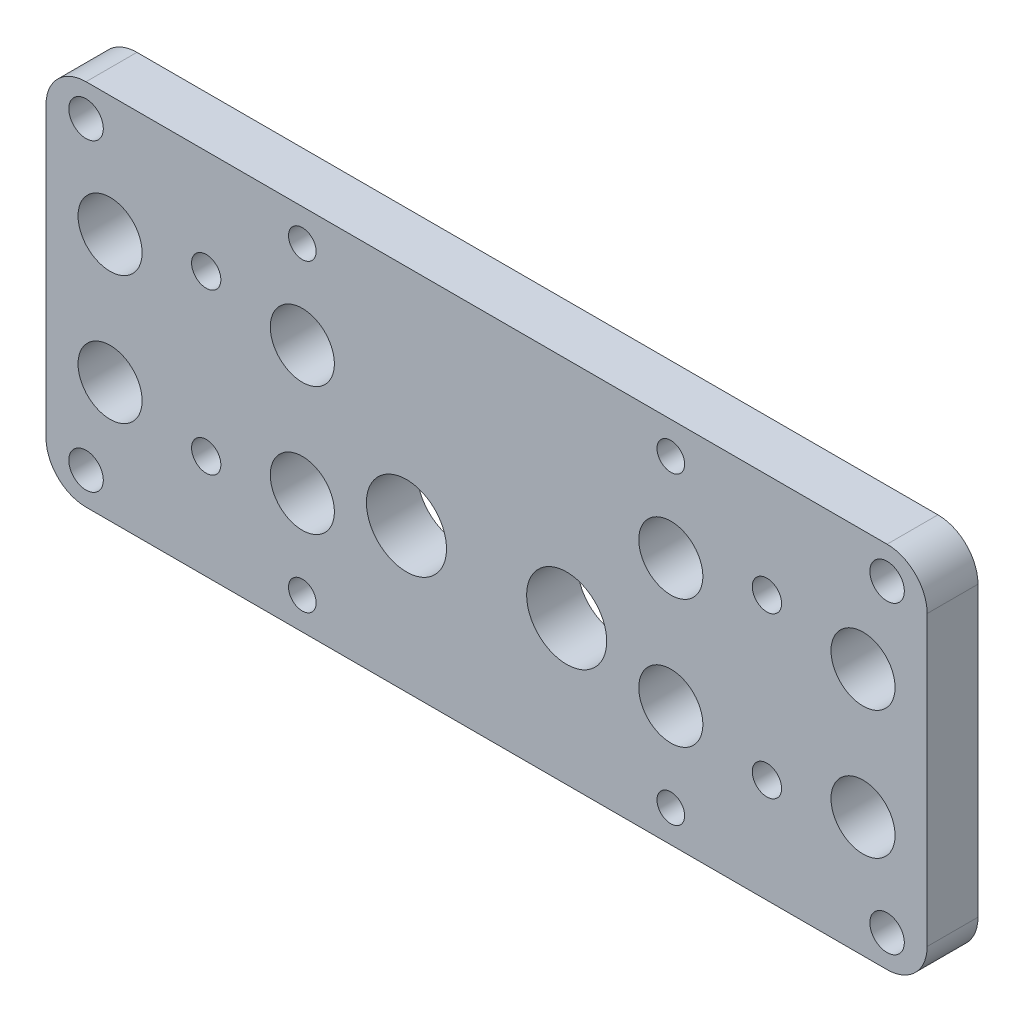
from build123d import *

# Parameters (mm, degrees)
SKETCH1_W             = 110
SKETCH1_H             = 46
BOSS_EXTRUDE1_DEPTH   = 6.35
SKETCH5_R             = 5
CUT_EXTRUDE1_DEPTH    = 7.35
SKETCH7_R             = 4
CUT_EXTRUDE2_DEPTH    = 7.35
FILLET1_R             = 5
F_8_32_TAPPED_HOLE1_D = 3.4544
F_8_CLEARANCE_HOLE1_D = 4.3053
F_6_CLEARANCE_HOLE2_D = 3.6576


with BuildPart() as part:
    # Sketch1 → Boss-Extrude1 (new body)
    with BuildSketch(Plane.XY):
        Rectangle(SKETCH1_W, SKETCH1_H)
    extrude(amount=BOSS_EXTRUDE1_DEPTH)

    # Sketch5 → Cut-Extrude1 (cut, through all)
    with BuildSketch(Plane(origin=(0, 0, 0), x_dir=(-1, 0, 0), z_dir=(0, 0, -1))):
        with Locations((-10, -5)):
            Circle(SKETCH5_R)
        with Locations((10, -5)):
            Circle(SKETCH5_R)
    extrude(amount=-CUT_EXTRUDE1_DEPTH, mode=Mode.SUBTRACT)

    # Sketch7 → Cut-Extrude2 (cut, through all)
    with BuildSketch(Plane(origin=(0, 0, 0), x_dir=(-1, 0, 0), z_dir=(0, 0, -1))):
        with Locations((-23, 8)):
            Circle(SKETCH7_R)
        with Locations((-23, -8)):
            Circle(SKETCH7_R)
        with Locations((23, -8)):
            Circle(SKETCH7_R)
        with Locations((23, 8)):
            Circle(SKETCH7_R)
        with Locations((-47, 8)):
            Circle(SKETCH7_R)
        with Locations((-47, -8)):
            Circle(SKETCH7_R)
        with Locations((47, 8)):
            Circle(SKETCH7_R)
        with Locations((47, -8)):
            Circle(SKETCH7_R)
    extrude(amount=-CUT_EXTRUDE2_DEPTH, mode=Mode.SUBTRACT)

    # Fillet1
    fillet1_edges = [part.edges().sort_by_distance(p)[0] for p in [
        (-55, -23, 3.175),
        (-55, 23, 3.175),
        (55, 23, 3.175),
        (55, -23, 3.175),
    ]]
    fillet(fillet1_edges, radius=FILLET1_R)

    # #8-32 Tapped Hole1 (through all)
    with Locations(Plane(origin=(0, 0, 0), x_dir=(-1, 0, 0), z_dir=(0, 0, -1))):
        with Locations((-23, 19), (23, 19), (23, -19), (-23, -19)):
            Hole(F_8_32_TAPPED_HOLE1_D / 2)

    # #8 Clearance Hole1 (through all)
    with Locations(Plane(origin=(0, 0, 0), x_dir=(-1, 0, 0), z_dir=(0, 0, -1))):
        with Locations((-50, 19), (-50, -19), (50, -19), (50, 19)):
            Hole(F_8_CLEARANCE_HOLE1_D / 2)

    # #6 Clearance Hole2 (through all)
    with Locations(Plane(origin=(0, 0, 0), x_dir=(-1, 0, 0), z_dir=(0, 0, -1))):
        with Locations((-35, 10), (-35, -10), (35, -10), (35, 10)):
            Hole(F_6_CLEARANCE_HOLE2_D / 2)


solid = part.part
